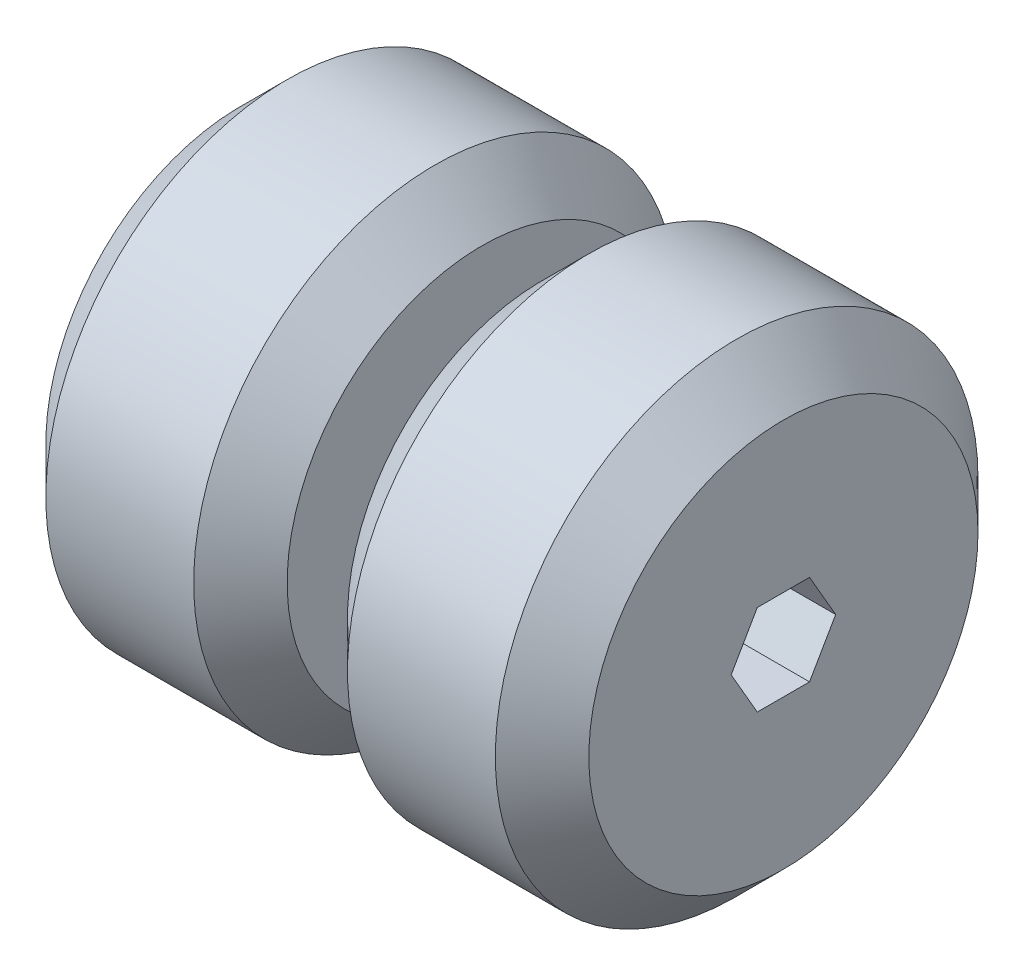
from build123d import *

# Parameters (mm, degrees)
BOSS_EXTRUDE1_START = -3.175
SKETCH1_R           = 25.4
BOSS_EXTRUDE1_DEPTH = 25.4
BOSS_EXTRUDE3_START = 3.175
SKETCH1_3_R         = 25.4
BOSS_EXTRUDE3_DEPTH = 25.4
CHAMFER1_SIZE       = 4.92
CHAMFER2_SIZE       = 4.92
SKETCH2_R           = 9.525
BOSS_EXTRUDE4_DEPTH = 6.35
CUT_EXTRUDE1_DEPTH  = 58.15


with BuildPart() as part:
    # Sketch1 → Boss-Extrude1 (new body)
    with BuildSketch(Plane(origin=(0, 0, 0), x_dir=(0, 0, -1), z_dir=(1, 0, 0)).offset(BOSS_EXTRUDE1_START)):
        Circle(SKETCH1_R)
    extrude(amount=-BOSS_EXTRUDE1_DEPTH)

    # Chamfer1
    chamfer1_edges = [part.edges().sort_by_distance(p)[0] for p in [
        (-3.175, 0, 25.4),
        (-28.575, 0, 25.4),
    ]]
    chamfer(chamfer1_edges, length=CHAMFER1_SIZE)



with BuildPart() as body_2:
    # Sketch1_3 → Boss-Extrude3 (new body)
    with BuildSketch(Plane(origin=(0, 0, 0), x_dir=(0, 0, -1), z_dir=(1, 0, 0)).offset(BOSS_EXTRUDE3_START)):
        Circle(SKETCH1_3_R)
    extrude(amount=BOSS_EXTRUDE3_DEPTH)

    # Chamfer2
    chamfer2_edges = [body_2.edges().sort_by_distance(p)[0] for p in [
        (3.175, 0, 25.4),
        (28.575, 0, 25.4),
    ]]
    chamfer(chamfer2_edges, length=CHAMFER2_SIZE)


with BuildPart() as part_1:
    add(part.part)

    add(body_2.part)  # Boss-Extrude4 merges body 2
    # Sketch2 → Boss-Extrude4 (add)
    with BuildSketch(Plane(origin=(-3.175, 0, 0), x_dir=(0, 0, -1), z_dir=(1, 0, 0))):
        Circle(SKETCH2_R)
    extrude(amount=BOSS_EXTRUDE4_DEPTH)

    # Sketch3 → Cut-Extrude1 (cut, through all)
    with BuildSketch(Plane(origin=(28.575, 0, 0), x_dir=(0, 0, -1), z_dir=(1, 0, 0))):
        Polygon((2.749630657, -4.7625), (5.499261314, 0), (2.749630657, 4.7625), (-2.749630657, 4.7625), (-5.499261314, 0), (-2.749630657, -4.7625), align=None)
    extrude(amount=-CUT_EXTRUDE1_DEPTH, mode=Mode.SUBTRACT)


solid = part_1.part
